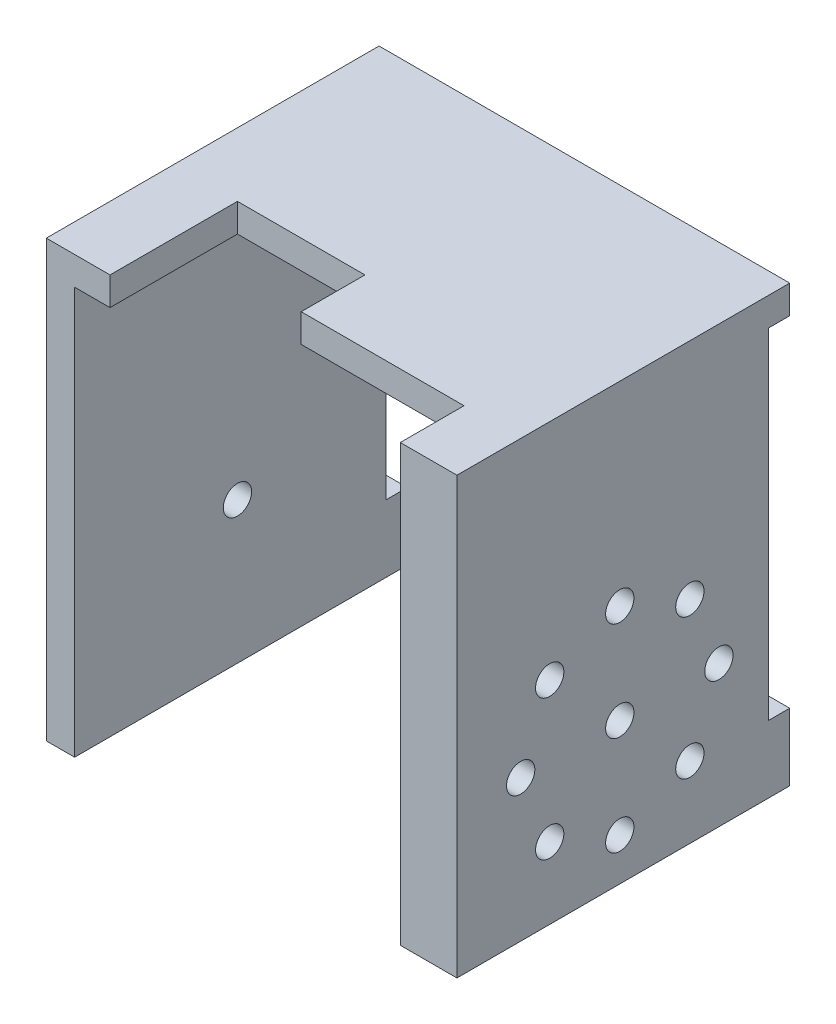
from build123d import *

# Parameters (mm, degrees)
EXTRUSION1_DEPTH = 47
ESQUISSE2_R      = 2
ESQUISSE2_W      = 3
ESQUISSE2_H      = 48
EXTRUSION2_DEPTH = 59
EXTRUSION3_REACH = 60
ESQUISSE3_R      = 2
EXTRUSION4_DEPTH = 5


with BuildPart() as part:
    # Esquisse1 → Extrusion1 (new body)
    with BuildSketch(Plane.XY):
        Polygon((0, -20), (0, 37.5), (46, 37.5), (46, -20), (54, -20), (54, 41.5), (-4, 41.5), (-4, -20), align=None)
    extrude(amount=EXTRUSION1_DEPTH)

    # Esquisse2 → Extrusion2 (cut, through all)
    with BuildSketch(Plane(origin=(54, 0, 0), x_dir=(0, 0, -1), z_dir=(1, 0, 0))):
        with Locations((-24, 0)):
            Circle(ESQUISSE2_R)
        with Locations((-1.5, 13.5)):
            Rectangle(ESQUISSE2_W, ESQUISSE2_H)
    extrude(amount=-EXTRUSION2_DEPTH, mode=Mode.SUBTRACT)

    # Esquisse3 → Extrusion3 (cut, up to next)
    with BuildSketch(Plane(origin=(54, 0, 0), x_dir=(0, 0, -1), z_dir=(1, 0, 0)), mode=Mode.PRIVATE) as extrusion3_sk1:
        with Locations((-24, 14)):
            Circle(ESQUISSE3_R)
    extrusion3_tool1 = extrude(extrusion3_sk1.sketch, amount=-EXTRUSION3_REACH, mode=Mode.PRIVATE) & part.part
    add(extrusion3_tool1.solids().sort_by_distance((54, 14, 24))[0], mode=Mode.SUBTRACT)
    # Esquisse3 → Extrusion3 (cut, up to next)
    with BuildSketch(Plane(origin=(54, 0, 0), x_dir=(0, 0, -1), z_dir=(1, 0, 0)), mode=Mode.PRIVATE) as extrusion3_sk2:
        with Locations((-14.100505063, 9.899494937)):
            Circle(ESQUISSE3_R)
    extrusion3_tool2 = extrude(extrusion3_sk2.sketch, amount=-EXTRUSION3_REACH, mode=Mode.PRIVATE) & part.part
    add(extrusion3_tool2.solids().sort_by_distance((54, 9.899495, 14.100505))[0], mode=Mode.SUBTRACT)
    # Esquisse3 → Extrusion3 (cut, up to next)
    with BuildSketch(Plane(origin=(54, 0, 0), x_dir=(0, 0, -1), z_dir=(1, 0, 0)), mode=Mode.PRIVATE) as extrusion3_sk3:
        with Locations((-10, 0)):
            Circle(ESQUISSE3_R)
    extrusion3_tool3 = extrude(extrusion3_sk3.sketch, amount=-EXTRUSION3_REACH, mode=Mode.PRIVATE) & part.part
    add(extrusion3_tool3.solids().sort_by_distance((54, 0, 10))[0], mode=Mode.SUBTRACT)
    # Esquisse3 → Extrusion3 (cut, up to next)
    with BuildSketch(Plane(origin=(54, 0, 0), x_dir=(0, 0, -1), z_dir=(1, 0, 0)), mode=Mode.PRIVATE) as extrusion3_sk4:
        with Locations((-14.100505063, -9.899494937)):
            Circle(ESQUISSE3_R)
    extrusion3_tool4 = extrude(extrusion3_sk4.sketch, amount=-EXTRUSION3_REACH, mode=Mode.PRIVATE) & part.part
    add(extrusion3_tool4.solids().sort_by_distance((54, -9.899495, 14.100505))[0], mode=Mode.SUBTRACT)
    # Esquisse3 → Extrusion3 (cut, up to next)
    with BuildSketch(Plane(origin=(54, 0, 0), x_dir=(0, 0, -1), z_dir=(1, 0, 0)), mode=Mode.PRIVATE) as extrusion3_sk5:
        with Locations((-24, -14)):
            Circle(ESQUISSE3_R)
    extrusion3_tool5 = extrude(extrusion3_sk5.sketch, amount=-EXTRUSION3_REACH, mode=Mode.PRIVATE) & part.part
    add(extrusion3_tool5.solids().sort_by_distance((54, -14, 24))[0], mode=Mode.SUBTRACT)
    # Esquisse3 → Extrusion3 (cut, up to next)
    with BuildSketch(Plane(origin=(54, 0, 0), x_dir=(0, 0, -1), z_dir=(1, 0, 0)), mode=Mode.PRIVATE) as extrusion3_sk6:
        with Locations((-33.899494937, -9.899494937)):
            Circle(ESQUISSE3_R)
    extrusion3_tool6 = extrude(extrusion3_sk6.sketch, amount=-EXTRUSION3_REACH, mode=Mode.PRIVATE) & part.part
    add(extrusion3_tool6.solids().sort_by_distance((54, -9.899495, 33.899495))[0], mode=Mode.SUBTRACT)
    # Esquisse3 → Extrusion3 (cut, up to next)
    with BuildSketch(Plane(origin=(54, 0, 0), x_dir=(0, 0, -1), z_dir=(1, 0, 0)), mode=Mode.PRIVATE) as extrusion3_sk7:
        with Locations((-38, 0)):
            Circle(ESQUISSE3_R)
    extrusion3_tool7 = extrude(extrusion3_sk7.sketch, amount=-EXTRUSION3_REACH, mode=Mode.PRIVATE) & part.part
    add(extrusion3_tool7.solids().sort_by_distance((54, 0, 38))[0], mode=Mode.SUBTRACT)
    # Esquisse3 → Extrusion3 (cut, up to next)
    with BuildSketch(Plane(origin=(54, 0, 0), x_dir=(0, 0, -1), z_dir=(1, 0, 0)), mode=Mode.PRIVATE) as extrusion3_sk8:
        with Locations((-33.899494937, 9.899494937)):
            Circle(ESQUISSE3_R)
    extrusion3_tool8 = extrude(extrusion3_sk8.sketch, amount=-EXTRUSION3_REACH, mode=Mode.PRIVATE) & part.part
    add(extrusion3_tool8.solids().sort_by_distance((54, 9.899495, 33.899495))[0], mode=Mode.SUBTRACT)

    # Esquisse4 → Extrusion4 (cut, through all)
    with BuildSketch(Plane.XZ.offset(-37.5)):
        Polygon((5, 47), (5, 29), (23, 29), (23, 38), (46, 38), (46, 47), (23, 47), align=None)
    extrude(amount=-EXTRUSION4_DEPTH, mode=Mode.SUBTRACT)


solid = part.part
